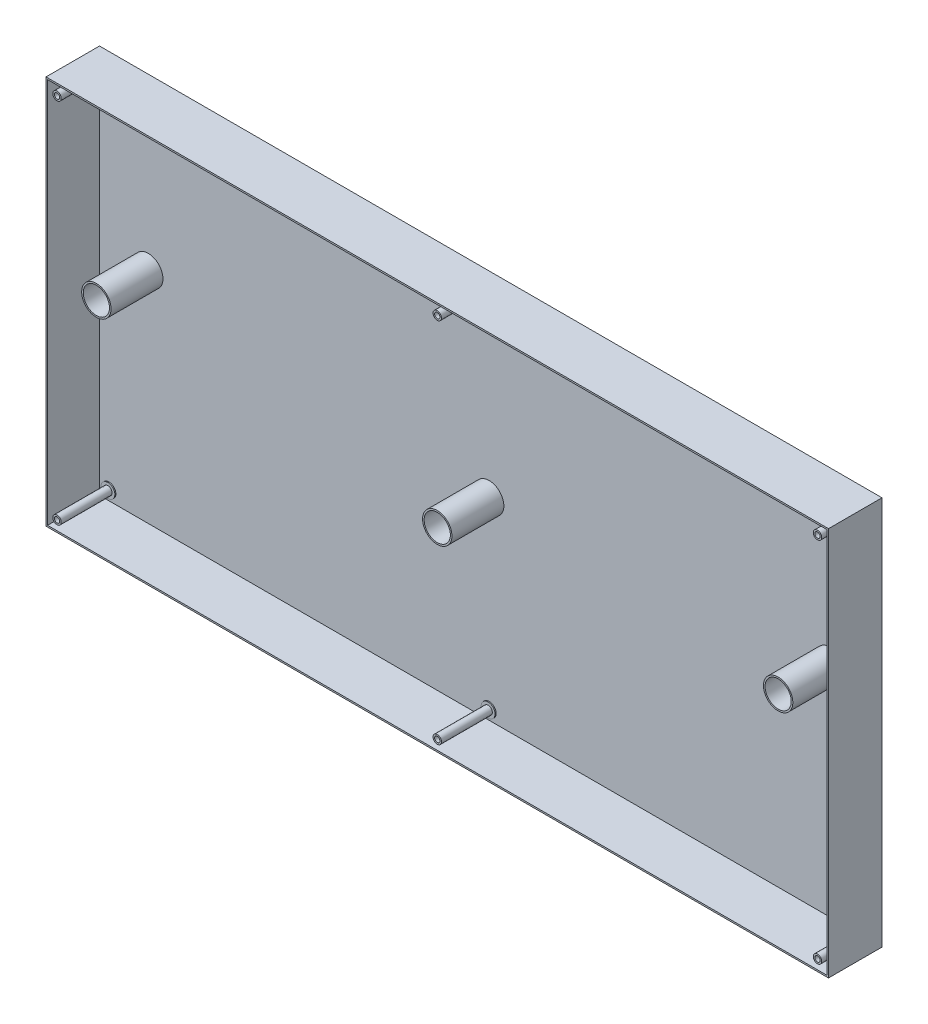
from build123d import *

# Parameters (mm, degrees)
SKETCH1_W                 = 1492
SKETCH1_H                 = 742
BOSS_EXTRUDE1_DEPTH       = 102
HOLE1_D                   = 10.1
HOLE1_DEPTH               = 102
HOLE1_CBORE_D             = 20.5
HOLE1_CBORE_DEPTH         = 2
M45_CLEARANCE_HOLE1_D     = 50
M45_CLEARANCE_HOLE1_DEPTH = 102
SHELL1_T                  = -3


with BuildPart() as part:
    # Sketch1 → Boss-Extrude1 (new body)
    with BuildSketch(Plane.XY.offset(102)):
        Rectangle(SKETCH1_W, SKETCH1_H)
    extrude(amount=-BOSS_EXTRUDE1_DEPTH)

    # Hole1
    with Locations(Plane(origin=(0, 0, 0), x_dir=(-1, 0, 0), z_dir=(0, 0, -1))):
        with Locations((725, 350), (-725, 350), (-725, -350), (725, -350), (0, 350), (0, -350)):
            CounterBoreHole(HOLE1_D / 2, HOLE1_CBORE_D / 2, HOLE1_CBORE_DEPTH, depth=HOLE1_DEPTH)

    # M45 Clearance Hole1
    with Locations(Plane.XY.offset(102)):
        with Locations((650, 50), (0, 0), (-650, 50)):
            Hole(M45_CLEARANCE_HOLE1_D / 2, depth=M45_CLEARANCE_HOLE1_DEPTH)

    # Shell1
    shell1_openings = [part.faces().sort_by_distance(p)[0] for p in [
        (675, 50, 102),
    ]]
    offset(amount=SHELL1_T, openings=shell1_openings, kind=Kind.INTERSECTION)


solid = part.part
